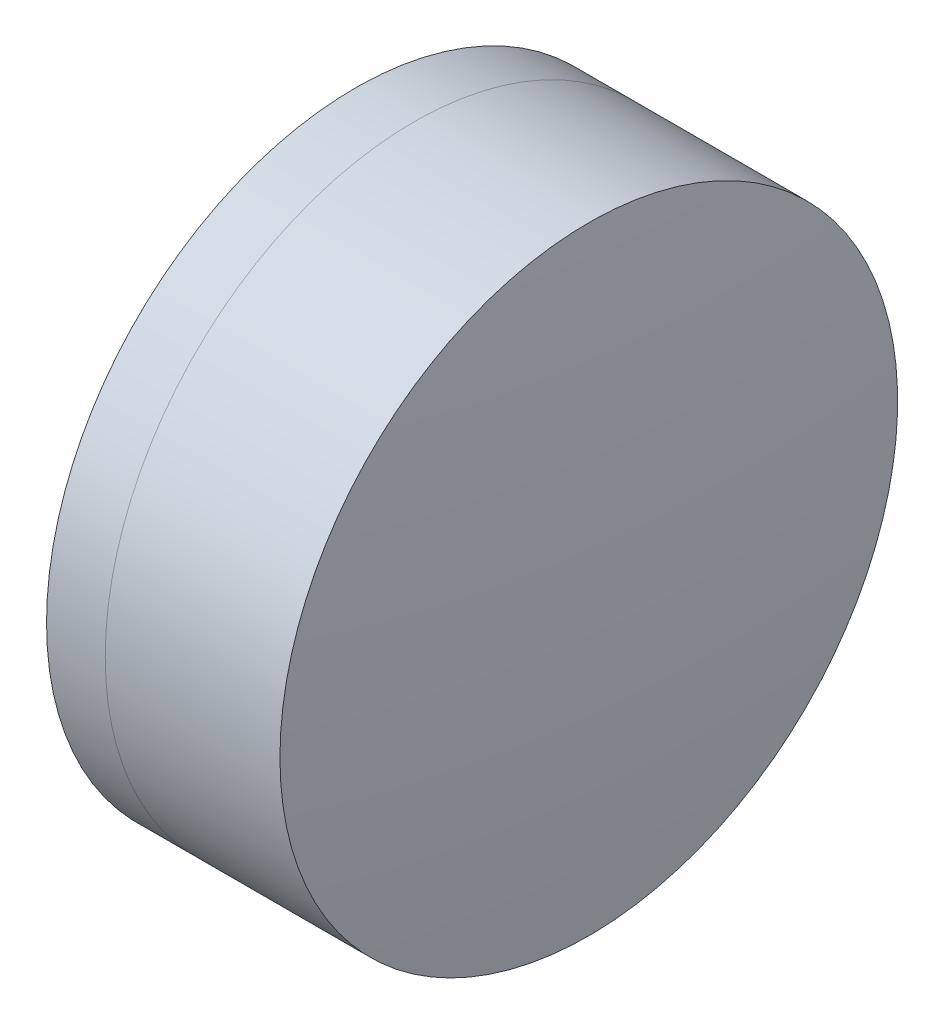
from build123d import *


with BuildPart() as part:
    # 草图1 one side → 旋转1 (revolve)
    with BuildSketch(Plane(origin=(0, 0, 0), x_dir=(1, 0, 0), z_dir=(0, 1, 0)), mode=Mode.PRIVATE) as revolve_1_sk:
        with BuildLine():
            ThreePointArc((264.356123725, 4), (263.792976008, 2.035134096), (263.603074491, 0))
            Line((263.603074491, 0), (266.103074491, 0))
            ThreePointArc((266.103074491, 0), (265.852717001, 2.059968433), (265.116221015, 4))
            Line((265.116221015, 4), (264.356123725, 4))
        make_face()
    revolve(revolve_1_sk.sketch.rotate(Axis((124.523309526, 0, 0), (1, 0, 0)), 180), axis=Axis((124.523309526, 0, 0), (1, 0, 0)))  # turned: the seam where the file's is


with BuildPart() as body_2:
    # 草图2 one side → 旋转3 (revolve)
    with BuildSketch(Plane(origin=(0, 0, 0), x_dir=(1, 0, 0), z_dir=(0, 1, 0)), mode=Mode.PRIVATE) as revolve_3_sk:
        with BuildLine():
            Line((267.378908986, 4), (265.116221015, 4))
            ThreePointArc((265.116221015, 4), (265.852717001, 2.059968433), (266.103074491, 0))
            Line((266.103074491, 0), (267.603074491, 0))
            ThreePointArc((267.603074491, 0), (267.546989182, 2.003138174), (267.378908986, 4))
        make_face()
    revolve(revolve_3_sk.sketch.rotate(Axis((-0.551919993, 0, 0), (1, 0, 0)), 180), axis=Axis((-0.551919993, 0, 0), (1, 0, 0)))  # turned: the seam where the file's is


solid = Compound([part.part, body_2.part])
